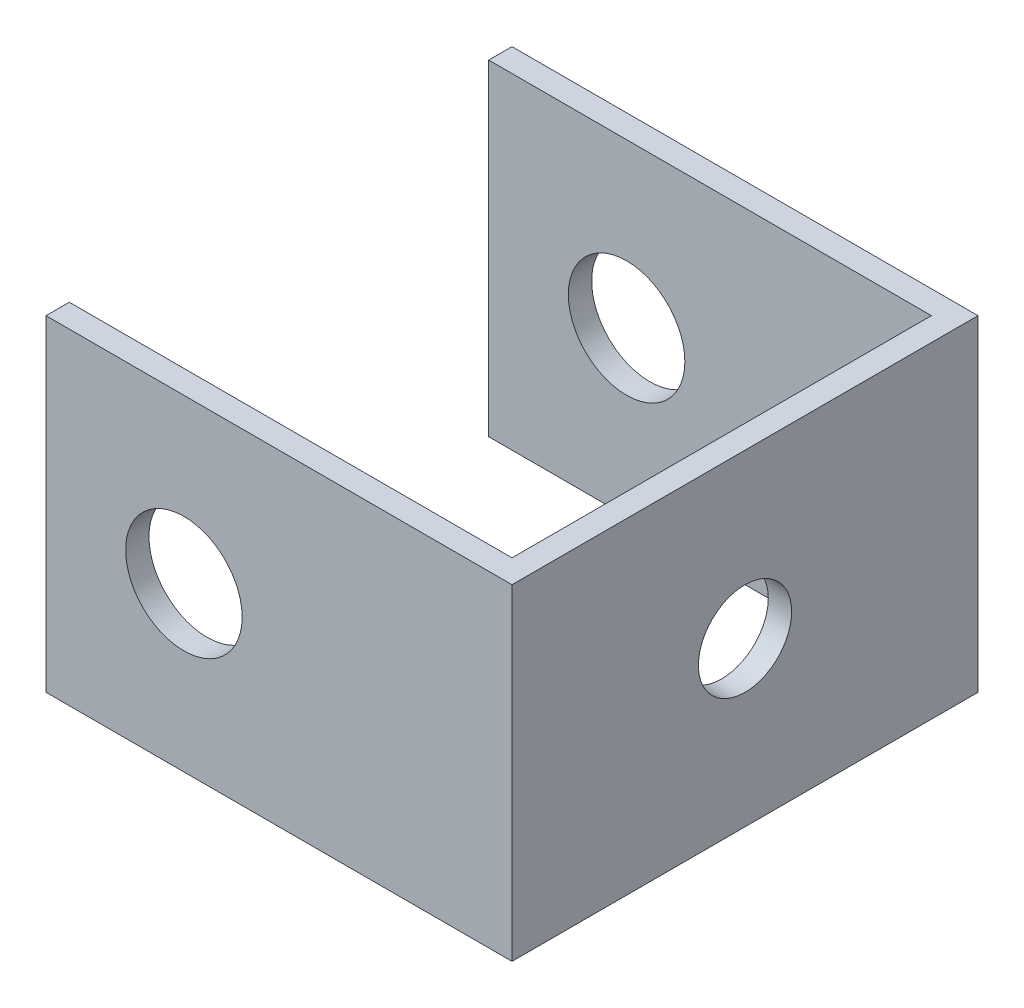
from build123d import *

# Parameters (mm, degrees)
BOSS_EXTRUDE1_DEPTH = 14
SKETCH2_R           = 2.5
CUT_EXTRUDE1_DEPTH  = 20
CUT_EXTRUDE2_REACH  = 22
SKETCH3_R           = 2


with BuildPart() as part:
    # Sketch1 → Boss-Extrude1 (new body)
    with BuildSketch(Plane(origin=(0, 0, 0), x_dir=(1, 0, 0), z_dir=(0, 1, 0))):
        Polygon((-10, -10), (10, -10), (10, 10), (-10, 10), (-10, 9), (9, 9), (9, -9), (-10, -9), align=None)
    extrude(amount=BOSS_EXTRUDE1_DEPTH)

    # Sketch2 → Cut-Extrude1 (cut)
    with BuildSketch(Plane.XY.offset(10)):
        with Locations((-4.081710117, 7)):
            Circle(SKETCH2_R)
    extrude(amount=-CUT_EXTRUDE1_DEPTH, mode=Mode.SUBTRACT)

    # Sketch3 → Cut-Extrude2 (cut, up to next)
    with BuildSketch(Plane(origin=(10, 0, 0), x_dir=(0, 0, -1), z_dir=(1, 0, 0)), mode=Mode.PRIVATE) as cut_extrude2_sk1:
        with Locations((0, 7)):
            Circle(SKETCH3_R)
    cut_extrude2_tool1 = extrude(cut_extrude2_sk1.sketch, amount=-CUT_EXTRUDE2_REACH, mode=Mode.PRIVATE) & part.part
    add(cut_extrude2_tool1.solids().sort_by_distance((10, 7, 0))[0], mode=Mode.SUBTRACT)


solid = part.part
